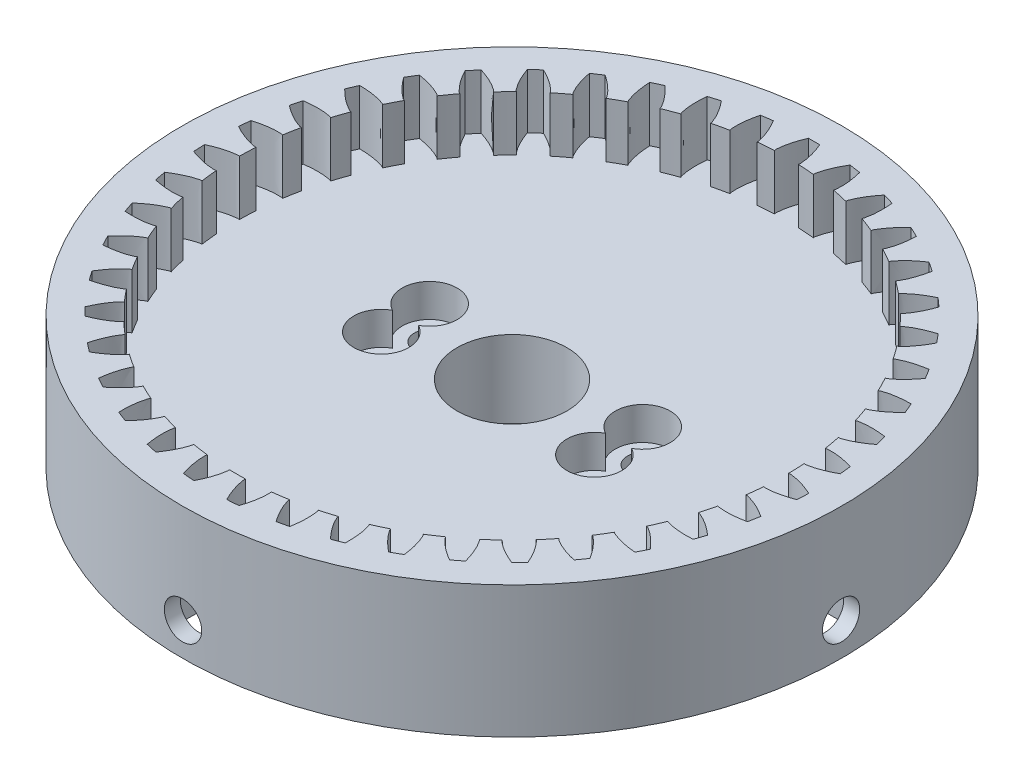
from build123d import *

# Parameters (mm, degrees)
SKETCH1_R           = 38.1
SKETCH1_R_2         = 31.75
SKETCH1_R_3         = 1.778
BOSS_EXTRUDE1_DEPTH = 5.08
SKETCH1_3_R         = 38.1
SKETCH1_3_R_2       = 31.75
BOSS_EXTRUDE2_DEPTH = 11.43
CUT_EXTRUDE1_DEPTH  = 6.35
CIRPATTERN1_COUNT   = 43
SKETCH4_R           = 38.1
SKETCH4_R_2         = 1.778
BOSS_EXTRUDE3_DEPTH = 3.81
SKETCH3_R           = 3.175
CUT_EXTRUDE2_DEPTH  = 3.81
SKETCH5_R           = 6.35
CUT_EXTRUDE3_DEPTH  = 9.89
SKETCH10_W          = 3.81
SKETCH10_H          = 7.366
SKETCH10_W_2        = 7.366
SKETCH10_H_2        = 3.81
CUT_EXTRUDE4_DEPTH  = 7.62
SKETCH14_R          = 2.159
CUT_EXTRUDE5_DEPTH  = 1.905
CIRPATTERN2_COUNT   = 4


with BuildPart() as part:
    # Sketch1 → Boss-Extrude1 (new body)
    with BuildSketch(Plane(origin=(0, 0, 0), x_dir=(1, 0, 0), z_dir=(0, 1, 0))):
        Circle(SKETCH1_R)
        Circle(SKETCH1_R_2, mode=Mode.SUBTRACT)
        Circle(SKETCH1_R_2)
        with Locations((12.319, -2.794)):
            Circle(SKETCH1_R_3, mode=Mode.SUBTRACT)
        with Locations((-12.319, -2.794)):
            Circle(SKETCH1_R_3, mode=Mode.SUBTRACT)
        with Locations((-12.319, 2.794)):
            Circle(SKETCH1_R_3, mode=Mode.SUBTRACT)
        with Locations((12.319, 2.794)):
            Circle(SKETCH1_R_3, mode=Mode.SUBTRACT)
    extrude(amount=BOSS_EXTRUDE1_DEPTH)

    # Sketch1_3 → Boss-Extrude2 (add)
    with BuildSketch(Plane(origin=(0, 0, 0), x_dir=(1, 0, 0), z_dir=(0, 1, 0))):
        Circle(SKETCH1_3_R)
        Circle(SKETCH1_3_R_2, mode=Mode.SUBTRACT)
    extrude(amount=BOSS_EXTRUDE2_DEPTH)

    # Sketch2 → Cut-Extrude1 (cut)
    with BuildSketch(Plane(origin=(0, 11.43, 0), x_dir=(1, 0, 0), z_dir=(0, 1, 0))):
        with BuildLine():
            add(Edge.make_bspline(
                [(1.384915549, 31.719781035), (1.425857102, 31.879447007), (1.396752612, 32.249594792), (1.309869775, 32.893193528), (1.080768362, 33.807322769), (0.832693868, 34.501279424), (0.659941443, 34.918764329)],
                knots=[0, 0, 0, 0, 0.111594225, 0.250457261, 0.444806254, 0.753448741, 0.753448741, 0.753448741, 0.753448741], degree=3))
            ThreePointArc((0.659941443, 34.918764329), (0, 34.925), (-0.659941443, 34.918764329))
            add(Edge.make_bspline(
                [(-1.384915549, 31.719781035), (-1.425857102, 31.879447007), (-1.396752612, 32.249594792), (-1.309869775, 32.893193528), (-1.080768362, 33.807322769), (-0.832693868, 34.501279424), (-0.659941443, 34.918764329)],
                knots=[0, 0, 0, 0, 0.111594225, 0.250457261, 0.444806254, 0.753448741, 0.753448741, 0.753448741, 0.753448741], degree=3))
            ThreePointArc((-1.384915549, 31.719781035), (0, 31.75), (1.384915549, 31.719781035))
        make_face()
    cut_extrude1 = extrude(amount=-CUT_EXTRUDE1_DEPTH, mode=Mode.SUBTRACT)

    # CirPattern1: Cut-Extrude1 ×43 about axis
    cirpattern1_axis = Axis((0, 11.43, 0), (0, -1, 0))
    for i in range(1, CIRPATTERN1_COUNT):
        add(cut_extrude1.rotate(cirpattern1_axis, i * 360 / CIRPATTERN1_COUNT), mode=Mode.SUBTRACT)

    # Sketch4 → Boss-Extrude3 (add)
    with BuildSketch(Plane.XZ):
        Circle(SKETCH4_R)
        with Locations((12.319, -2.794)):
            Circle(SKETCH4_R_2, mode=Mode.SUBTRACT)
        with Locations((12.319, 2.794)):
            Circle(SKETCH4_R_2, mode=Mode.SUBTRACT)
        with Locations((-12.319, 2.794)):
            Circle(SKETCH4_R_2, mode=Mode.SUBTRACT)
        with Locations((-12.319, -2.794)):
            Circle(SKETCH4_R_2, mode=Mode.SUBTRACT)
    extrude(amount=BOSS_EXTRUDE3_DEPTH)

    # Sketch3 → Cut-Extrude2 (cut)
    with BuildSketch(Plane(origin=(0, 5.08, 0), x_dir=(1, 0, 0), z_dir=(0, 1, 0))):
        with Locations((-12.319, -2.794)):
            Circle(SKETCH3_R)
        with Locations((-12.319, 2.794)):
            Circle(SKETCH3_R)
        with Locations((12.319, 2.794)):
            Circle(SKETCH3_R)
        with Locations((12.319, -2.794)):
            Circle(SKETCH3_R)
    extrude(amount=-CUT_EXTRUDE2_DEPTH, mode=Mode.SUBTRACT)

    # Sketch5 → Cut-Extrude3 (cut, through all)
    with BuildSketch(Plane(origin=(0, 5.08, 0), x_dir=(1, 0, 0), z_dir=(0, 1, 0))):
        Circle(SKETCH5_R)
    extrude(amount=-CUT_EXTRUDE3_DEPTH, mode=Mode.SUBTRACT)

    # Sketch10 → Cut-Extrude4 (cut)
    with BuildSketch(Plane.XZ.offset(3.81)):
        with Locations((34.29, 0)):
            Rectangle(SKETCH10_W, SKETCH10_H)
        with Locations((0, 34.29)):
            Rectangle(SKETCH10_W_2, SKETCH10_H_2)
        with Locations((0, -34.29)):
            Rectangle(SKETCH10_W_2, SKETCH10_H_2)
        with Locations((-34.29, 0)):
            Rectangle(SKETCH10_W, SKETCH10_H)
    extrude(amount=-CUT_EXTRUDE4_DEPTH, mode=Mode.SUBTRACT)

    # Sketch14 → Cut-Extrude5 (cut)
    with BuildSketch(Plane.XY.offset(-36.195)):
        Circle(SKETCH14_R)
    cut_extrude5 = extrude(amount=-CUT_EXTRUDE5_DEPTH, mode=Mode.SUBTRACT)

    # CirPattern2: Cut-Extrude5 ×4 about axis
    cirpattern2_axis = Axis((0, 5.08, 0), (0, -1, 0))
    for i in range(1, CIRPATTERN2_COUNT):
        add(cut_extrude5.rotate(cirpattern2_axis, i * 360 / CIRPATTERN2_COUNT), mode=Mode.SUBTRACT)


solid = part.part
